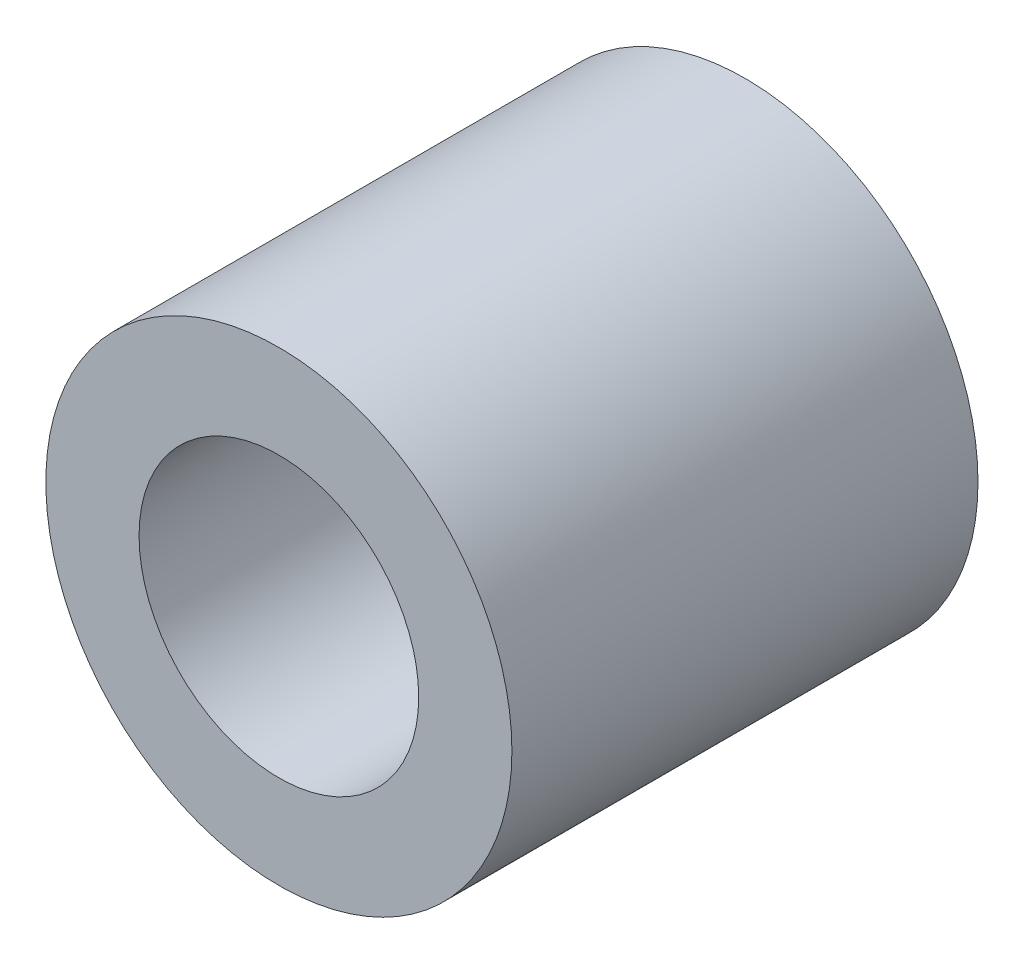
from build123d import *

# Parameters (mm, degrees)
SKETCH1_R           = 5
SKETCH1_R_2         = 3
BOSS_EXTRUDE1_DEPTH = 10


with BuildPart() as part:
    # Sketch1 → Boss-Extrude1 (new body)
    with BuildSketch(Plane.XY):
        Circle(SKETCH1_R)
        Circle(SKETCH1_R_2, mode=Mode.SUBTRACT)
    extrude(amount=BOSS_EXTRUDE1_DEPTH)


solid = part.part
